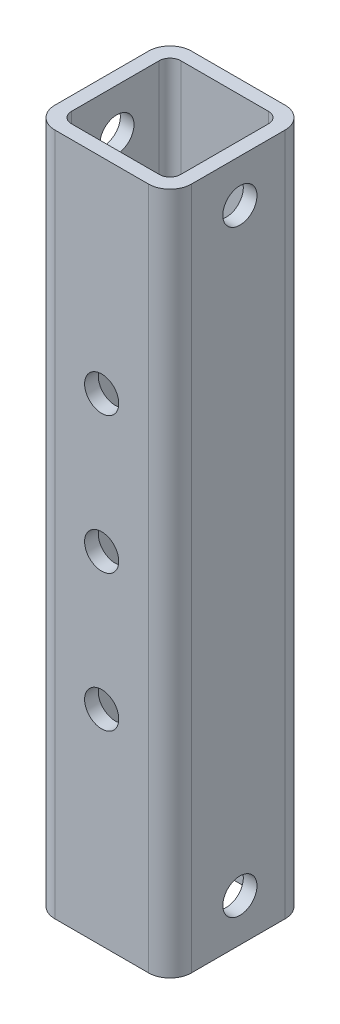
from build123d import *

# Parameters (mm, degrees)
BOSS_EXTRUDE1_DEPTH     = 127
SKETCH2_R               = 3.175
CUT_EXTRUDE1_DEPTH      = 25.4
SKETCH3_R               = 3.175
CUT_EXTRUDE2_DEPTH      = 1
CUT_EXTRUDE2_DEPTH_BACK = 26.4


with BuildPart() as part:
    # Sketch1 → Boss-Extrude1 (new body)
    with BuildSketch(Plane(origin=(0, 0, 0), x_dir=(1, 0, 0), z_dir=(0, 1, 0))):
        with BuildLine():
            Line((4, 0), (21.4, 0))
            ThreePointArc((21.4, 0), (24.228427125, 1.171572875), (25.4, 4))
            Line((25.4, 4), (25.4, 21.4))
            ThreePointArc((25.4, 21.4), (24.228427125, 24.228427125), (21.4, 25.4))
            Line((21.4, 25.4), (4, 25.4))
            ThreePointArc((4, 25.4), (1.171572875, 24.228427125), (0, 21.4))
            Line((0, 21.4), (0, 4))
            ThreePointArc((0, 4), (1.171572875, 1.171572875), (4, 0))
        make_face()
        with BuildLine():
            Line((20.86, 2.54), (4.54, 2.54))
            ThreePointArc((4.54, 2.54), (3.125786438, 3.125786438), (2.54, 4.54))
            Line((2.54, 4.54), (2.54, 20.86))
            ThreePointArc((2.54, 20.86), (3.125786438, 22.274213562), (4.54, 22.86))
            Line((4.54, 22.86), (20.86, 22.86))
            ThreePointArc((20.86, 22.86), (22.274213562, 22.274213562), (22.86, 20.86))
            Line((22.86, 20.86), (22.86, 4.54))
            ThreePointArc((22.86, 4.54), (22.274213562, 3.125786438), (20.86, 2.54))
        make_face(mode=Mode.SUBTRACT)
    extrude(amount=BOSS_EXTRUDE1_DEPTH)

    # Sketch2 → Cut-Extrude1 (cut)
    with BuildSketch(Plane(origin=(0, 0, 0), x_dir=(0, 0, -1), z_dir=(1, 0, 0))):
        with Locations((12.9921, 7.9375)):
            Circle(SKETCH2_R)
        with Locations((12.9921, 119.0625)):
            Circle(SKETCH2_R)
    extrude(amount=CUT_EXTRUDE1_DEPTH, mode=Mode.SUBTRACT)

    # Sketch3 → Cut-Extrude2 (cut, two sides)
    with BuildSketch(Plane(origin=(0, 0, -25.4), x_dir=(-1, 0, 0), z_dir=(0, 0, -1))) as cut_extrude2_sk:
        with Locations((-12.699512574, 88.9)):
            Circle(SKETCH3_R)
        with Locations((-12.699512574, 63.5)):
            Circle(SKETCH3_R)
        with Locations((-12.699512574, 38.1)):
            Circle(SKETCH3_R)
    extrude(amount=CUT_EXTRUDE2_DEPTH, mode=Mode.SUBTRACT)
    extrude(cut_extrude2_sk.sketch, amount=-CUT_EXTRUDE2_DEPTH_BACK, mode=Mode.SUBTRACT)


solid = part.part
